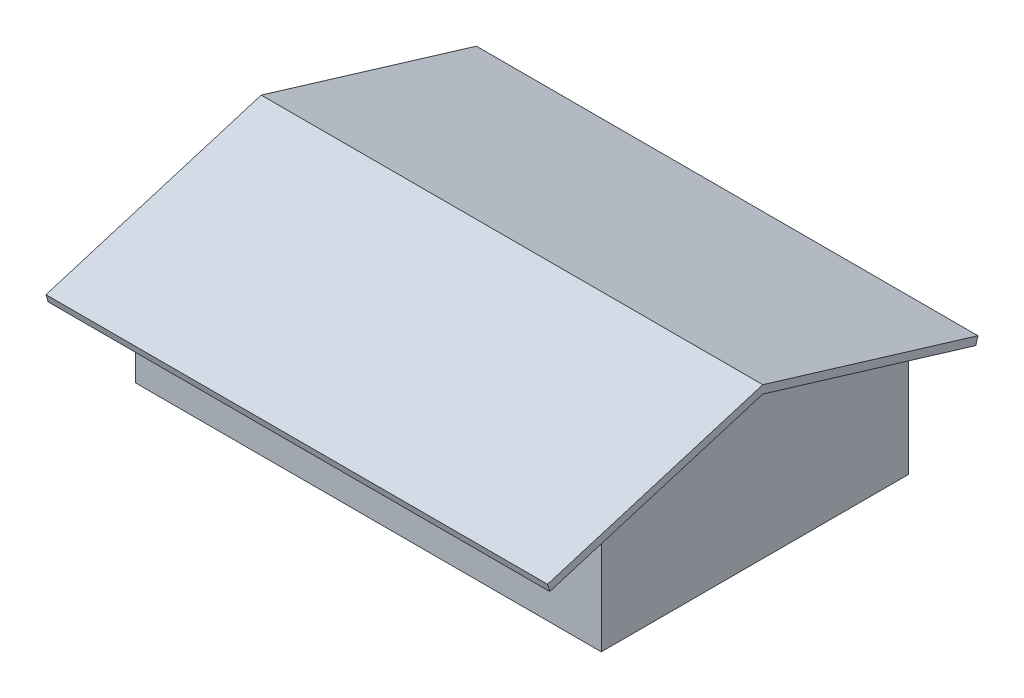
from build123d import *

# Parameters (mm, degrees)
BOSS_EXTRUDE1_DEPTH = 7620
BOSS_EXTRUDE2_START = 7620
BOSS_EXTRUDE2_DEPTH = 254
BOSS_EXTRUDE3_START = -7620
BOSS_EXTRUDE3_DEPTH = 914.4


with BuildPart() as part:
    # Sketch1 → Boss-Extrude1 (new body, symmetric)
    with BuildSketch(Plane(origin=(0, 0, 0), x_dir=(0, 0, -1), z_dir=(1, 0, 0))):
        Polygon((-5029.2, 0), (5029.2, 0), (5029.2, 3392.19401994), (6967.218121598, 2804.915801274), (7040.88, 3048), (5029.2, 3657.6), (0, 5181.6), (-5029.2, 3657.6), (-7040.88, 3048), (-6967.218121598, 2804.915801274), (-5029.2, 3392.19401994), align=None)
    extrude(amount=BOSS_EXTRUDE1_DEPTH, both=True)

    # Sketch2 → Boss-Extrude2 (add)
    with BuildSketch(Plane(origin=(0, 0, 0), x_dir=(0, 0, -1), z_dir=(1, 0, 0)).offset(BOSS_EXTRUDE2_START)):
        Polygon((-6967.218121598, 2804.915801274), (-5029.2, 3392.19401994), (0, 4916.19401994), (5029.2, 3392.19401994), (6967.218121598, 2804.915801274), (7040.88, 3048), (0, 5181.6), (-7040.88, 3048), align=None)
    extrude(amount=BOSS_EXTRUDE2_DEPTH)

    # Sketch2_2 → Boss-Extrude3 (add)
    with BuildSketch(Plane(origin=(0, 0, 0), x_dir=(0, 0, -1), z_dir=(1, 0, 0)).offset(BOSS_EXTRUDE3_START)):
        Polygon((-6967.218121598, 2804.915801274), (-5029.2, 3392.19401994), (0, 4916.19401994), (5029.2, 3392.19401994), (6967.218121598, 2804.915801274), (7040.88, 3048), (0, 5181.6), (-7040.88, 3048), align=None)
    extrude(amount=-BOSS_EXTRUDE3_DEPTH)


solid = part.part
